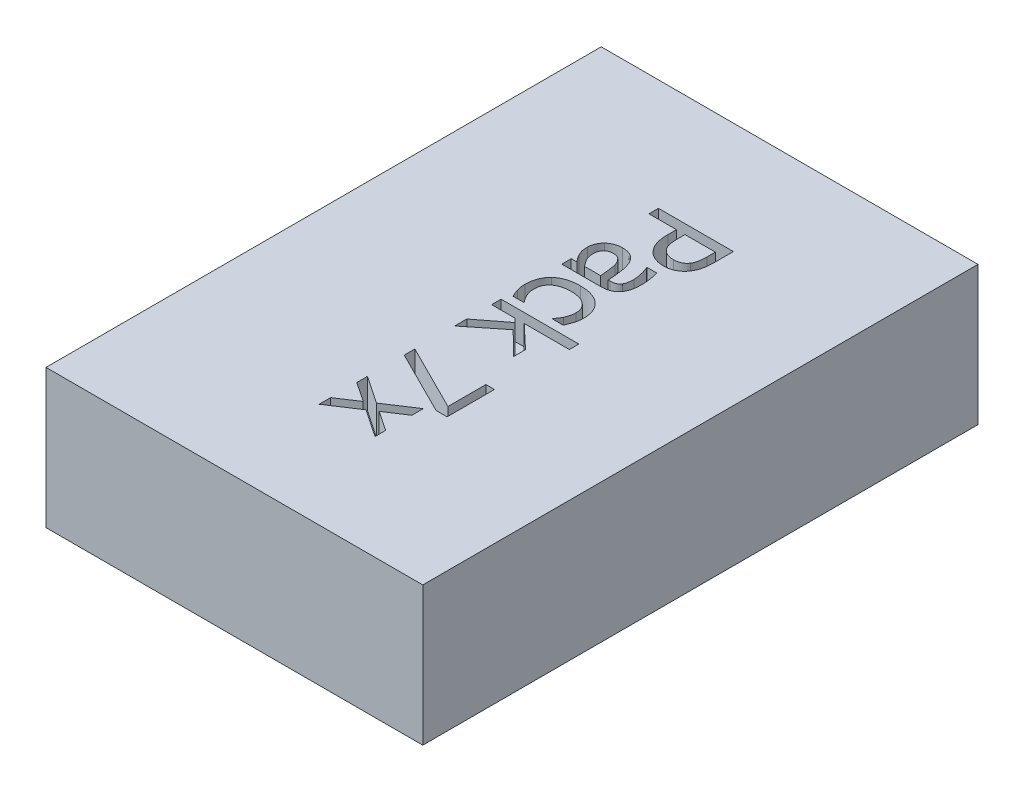
from build123d import *

# Parameters (mm, degrees)
SKETCH1_W           = 38
SKETCH1_H           = 14
BOSS_EXTRUDE1_DEPTH = 56
CUT_EXTRUDE1_DEPTH  = 3


with BuildPart() as part:
    # Sketch1 → Boss-Extrude1 (new body)
    with BuildSketch(Plane.XY):
        Rectangle(SKETCH1_W, SKETCH1_H)
    extrude(amount=BOSS_EXTRUDE1_DEPTH)

    # Sketch2 → Cut-Extrude1 (cut)
    with BuildSketch(Plane(origin=(0, 7, 0), x_dir=(1, 0, 0), z_dir=(0, 1, 0))):
        with BuildLine():
            add(Edge.make_bspline(
                [(3.247819021, -16.001203397), (3.166017395, -15.999505775), (3.003662304, -15.996136435), (2.764297073, -15.959652494), (2.531343241, -15.905343398), (2.307750042, -15.826775929), (2.094742675, -15.731458665), (1.898188136, -15.614545571), (1.715028941, -15.484211033), (1.607405271, -15.381596731), (1.553765815, -15.330453935)],
                knots=[0, 0, 0, 0, 0.000245218, 0.000486695, 0.000724751, 0.000961915, 0.001196573, 0.001423573, 0.00164708, 0.001869161, 0.001869161, 0.001869161, 0.001869161], degree=3))
            add(Edge.make_bspline(
                [(1.553765815, -15.330453935), (1.490690236, -15.263236352), (1.364664717, -15.128935074), (1.208368294, -14.900417457), (1.070026889, -14.658608827), (0.956698106, -14.395418802), (0.869496109, -14.104784869), (0.807935038, -13.782006196), (0.770776554, -13.42414577), (0.766980665, -13.173892861), (0.765000301, -13.04333272)],
                knots=[0, 0, 0, 0, 0.000276157, 0.000551763, 0.000828037, 0.00111109, 0.001409285, 0.001736539, 0.002095523, 0.0024871, 0.0024871, 0.0024871, 0.0024871], degree=3))
            Line((0.765000301, -13.04333272), (0.765000301, -12.176885755))
            Line((0.765000301, -12.176885755), (-2.007629989, -12.176885755))
            Line((-2.007629989, -12.176885755), (-2.007629989, -11.220806344))
            Line((-2.007629989, -11.220806344), (5.545397354, -11.220806344))
            Line((5.545397354, -11.220806344), (5.545397354, -13.122508047))
            add(Edge.make_bspline(
                [(5.545397354, -13.122508047), (5.543922544, -13.230596056), (5.541085497, -13.438521622), (5.520745917, -13.737857764), (5.484996583, -14.012211973), (5.436338134, -14.263551645), (5.371869763, -14.4957725), (5.28927761, -14.711729631), (5.190167504, -14.914523817), (5.108984036, -15.038908552), (5.068851523, -15.100397327)],
                knots=[0, 0, 0, 0, 0.000324257, 0.000623763, 0.000899483, 0.001153784, 0.001391202, 0.001621476, 0.001846621, 0.002066728, 0.002066728, 0.002066728, 0.002066728], degree=3))
            add(Edge.make_bspline(
                [(5.068851523, -15.100397327), (5.018725731, -15.168500818), (4.919494112, -15.303322021), (4.741782651, -15.480824552), (4.545099061, -15.634761619), (4.33037673, -15.768187733), (4.093134351, -15.87411868), (3.832096463, -15.94795925), (3.547686736, -15.993455227), (3.350079722, -15.998561121), (3.247819021, -16.001203397)],
                knots=[0, 0, 0, 0, 0.000253396, 0.000501635, 0.000750579, 0.001001412, 0.001258206, 0.001527224, 0.001813101, 0.002119709, 0.002119709, 0.002119709, 0.002119709], degree=3))
        make_face()
        with BuildLine():
            add(Edge.make_bspline(
                [(3.223917036, -14.949516045), (3.288234658, -14.947762396), (3.412914767, -14.944362936), (3.593401558, -14.91911716), (3.760270828, -14.875733826), (3.914536132, -14.815704042), (4.056140104, -14.738447022), (4.182183333, -14.640530147), (4.29865251, -14.528938843), (4.360661088, -14.440278397), (4.392126565, -14.395288762)],
                knots=[0, 0, 0, 0, 0.000192918, 0.000373973, 0.000545359, 0.000709032, 0.00086951, 0.001027268, 0.001186777, 0.001351103, 0.001351103, 0.001351103, 0.001351103], degree=3))
            add(Edge.make_bspline(
                [(4.392126565, -14.395288762), (4.418174298, -14.354073576), (4.471060507, -14.270392013), (4.529750909, -14.131861513), (4.582469222, -13.985767795), (4.620244151, -13.82673694), (4.650434169, -13.653165097), (4.670764223, -13.461036231), (4.682178311, -13.24962905), (4.683986018, -13.102106481), (4.684925885, -13.025406231)],
                knots=[0, 0, 0, 0, 0.000146033, 0.0002965, 0.00045005, 0.000611644, 0.000786018, 0.000978374, 0.001190841, 0.001420941, 0.001420941, 0.001420941, 0.001420941], degree=3))
            Line((4.684925885, -13.025406231), (4.684925885, -12.176885755))
            Line((4.684925885, -12.176885755), (1.625471771, -12.176885755))
            Line((1.625471771, -12.176885755), (1.625471771, -12.874524949))
            add(Edge.make_bspline(
                [(1.625471771, -12.874524949), (1.626346609, -12.973158383), (1.628009853, -13.160680306), (1.647617026, -13.427003126), (1.678102295, -13.663635985), (1.720536308, -13.873641097), (1.780087162, -14.060852664), (1.860877965, -14.229355242), (1.959716739, -14.382815713), (2.041895714, -14.471082164), (2.082597239, -14.514798688)],
                knots=[0, 0, 0, 0, 0.000295847, 0.000562465, 0.000800573, 0.00101123, 0.001204449, 0.001388202, 0.001570509, 0.001749407, 0.001749407, 0.001749407, 0.001749407], degree=3))
            add(Edge.make_bspline(
                [(2.082597239, -14.514798688), (2.121123908, -14.551129631), (2.196798579, -14.622491424), (2.322642342, -14.711343495), (2.450584854, -14.788752122), (2.585943778, -14.849641585), (2.730138763, -14.894186189), (2.88455006, -14.927137172), (3.05062549, -14.946611097), (3.165105632, -14.948530169), (3.223917036, -14.949516045)],
                knots=[0, 0, 0, 0, 0.000158674, 0.000311671, 0.000461036, 0.000606801, 0.000755628, 0.000912967, 0.001079921, 0.001256299, 0.001256299, 0.001256299, 0.001256299], degree=3))
        make_face(mode=Mode.SUBTRACT)
        with BuildLine():
            add(Edge.make_bspline(
                [(-1.441451713, -20.016736921), (-1.457424795, -19.995851723), (-1.491972199, -19.950680138), (-1.546770282, -19.877237547), (-1.611071154, -19.795090461), (-1.707533725, -19.677384419), (-1.819666444, -19.524797571), (-1.8923424, -19.393561549), (-1.926960789, -19.331048719)],
                knots=[0, 0, 0, 0, 7.8879e-05, 0.000170603, 0.000274897, 0.000391782, 0.000627265, 0.000841468, 0.000841468, 0.000841468, 0.000841468], degree=3))
            add(Edge.make_bspline(
                [(-1.926960789, -19.331048719), (-1.96668949, -19.249517445), (-2.043551674, -19.091780807), (-2.120256143, -18.885527112), (-2.164470294, -18.710076371), (-2.182571356, -18.556613778), (-2.197005924, -18.380224534), (-2.198206, -18.255002519), (-2.198845871, -18.188235049)],
                knots=[0, 0, 0, 0, 0.000272008, 0.000526248, 0.000658496, 0.00081378, 0.000989079, 0.001189309, 0.001189309, 0.001189309, 0.001189309], degree=3))
            add(Edge.make_bspline(
                [(-2.198845871, -18.188235049), (-2.196882187, -18.130898804), (-2.192989252, -18.017231736), (-2.169150981, -17.848782749), (-2.126789357, -17.685237961), (-2.068217129, -17.526857601), (-1.995728061, -17.374949412), (-1.908036094, -17.232289354), (-1.808586593, -17.098143203), (-1.731190509, -17.01822722), (-1.692422559, -16.978197045)],
                knots=[0, 0, 0, 0, 0.000172029, 0.000341042, 0.000509161, 0.000677889, 0.000846935, 0.001013212, 0.001179629, 0.00134665, 0.00134665, 0.00134665, 0.00134665], degree=3))
            add(Edge.make_bspline(
                [(-1.692422559, -16.978197045), (-1.65125364, -16.941539691), (-1.568167503, -16.867558689), (-1.429324361, -16.769834521), (-1.27635256, -16.684866063), (-1.11110933, -16.612586406), (-0.937220773, -16.551966014), (-0.756225836, -16.511230911), (-0.570819051, -16.484469488), (-0.445629909, -16.480998914), (-0.382294991, -16.479243102)],
                knots=[0, 0, 0, 0, 0.000165274, 0.000333552, 0.000508105, 0.000689364, 0.000874079, 0.001059614, 0.001245108, 0.001435041, 0.001435041, 0.001435041, 0.001435041], degree=3))
            add(Edge.make_bspline(
                [(-0.382294991, -16.479243102), (-0.286987744, -16.481820959), (-0.10213739, -16.486820765), (0.163779871, -16.533566762), (0.40801991, -16.611311031), (0.63000501, -16.721721927), (0.833224963, -16.863133933), (1.009552455, -17.044956932), (1.168381083, -17.258992831), (1.249049466, -17.422378107), (1.290843977, -17.507028469)],
                knots=[0, 0, 0, 0, 0.000285721, 0.000554161, 0.000806909, 0.001052095, 0.001295395, 0.001545747, 0.001808686, 0.00209138, 0.00209138, 0.00209138, 0.00209138], degree=3))
            add(Edge.make_bspline(
                [(1.290843977, -17.507028469), (1.326132356, -17.58914532), (1.398562486, -17.75769186), (1.482374065, -18.027999544), (1.549636371, -18.319183154), (1.598163266, -18.630595832), (1.637464118, -18.958680566), (1.671763242, -19.300358567), (1.700334937, -19.654469531), (1.714091732, -19.894705358), (1.721079712, -20.016736921)],
                knots=[0, 0, 0, 0, 0.000267983, 0.00055004, 0.000847546, 0.001163871, 0.001494989, 0.001838807, 0.002193991, 0.002560675, 0.002560675, 0.002560675, 0.002560675], degree=3))
            Line((1.721079712, -20.016736921), (1.904826224, -20.016736921))
            add(Edge.make_bspline(
                [(1.904826224, -20.016736921), (1.958682079, -20.015897713), (2.060813641, -20.014306248), (2.205880092, -19.994220451), (2.335011277, -19.963908315), (2.44907108, -19.920127409), (2.548850155, -19.86482269), (2.634449303, -19.7974387), (2.711344345, -19.723559287), (2.750346816, -19.664983629), (2.769779316, -19.635799031)],
                knots=[0, 0, 0, 0, 0.000161449, 0.00030617, 0.000438418, 0.000558542, 0.000671574, 0.000779144, 0.000884777, 0.000989667, 0.000989667, 0.000989667, 0.000989667], degree=3))
            add(Edge.make_bspline(
                [(2.769779316, -19.635799031), (2.788486, -19.604839727), (2.827064035, -19.540993611), (2.870822358, -19.435352306), (2.903987776, -19.319437768), (2.934155276, -19.15130751), (2.959540905, -18.93044839), (2.96249142, -18.751008581), (2.963982946, -18.660299258)],
                knots=[0, 0, 0, 0, 0.000108396, 0.000223541, 0.000341736, 0.000469478, 0.000735576, 0.001007609, 0.001007609, 0.001007609, 0.001007609], degree=3))
            add(Edge.make_bspline(
                [(2.963982946, -18.660299258), (2.962710327, -18.603494173), (2.960058949, -18.485146274), (2.941233847, -18.300518524), (2.909098284, -18.101781507), (2.850834842, -17.815739472), (2.753132051, -17.44592558), (2.639306518, -17.158431371), (2.581551182, -17.012556148)],
                knots=[0, 0, 0, 0, 0.000170406, 0.000355025, 0.000556172, 0.000774145, 0.001230755, 0.001701088, 0.001701088, 0.001701088, 0.001701088], degree=3))
            Line((2.581551182, -17.012556148), (2.581551182, -16.957282808))
            Line((2.581551182, -16.957282808), (3.563026451, -16.957282808))
            add(Edge.make_bspline(
                [(3.563026451, -16.957282808), (3.576206078, -17.005523929), (3.605046727, -17.111088781), (3.646565168, -17.284405914), (3.689436514, -17.486218598), (3.733698946, -17.711078434), (3.77362351, -17.949481382), (3.804440574, -18.192049394), (3.820403866, -18.433508801), (3.823110733, -18.594051249), (3.824454415, -18.673744124)],
                knots=[0, 0, 0, 0, 0.000150021, 0.000328287, 0.000534561, 0.000768942, 0.001015761, 0.001259606, 0.001502171, 0.001741266, 0.001741266, 0.001741266, 0.001741266], degree=3))
            add(Edge.make_bspline(
                [(3.824454415, -18.673744124), (3.823190404, -18.766379215), (3.820762184, -18.944335122), (3.805690684, -19.199871862), (3.775028282, -19.432642427), (3.735871997, -19.645826397), (3.680743874, -19.842975358), (3.605728257, -20.026970619), (3.51656203, -20.203056793), (3.439959915, -20.309923221), (3.401688051, -20.363315708)],
                knots=[0, 0, 0, 0, 0.000277925, 0.000533905, 0.000767375, 0.000981839, 0.001183755, 0.001380158, 0.00157727, 0.001774082, 0.001774082, 0.001774082, 0.001774082], degree=3))
            add(Edge.make_bspline(
                [(3.401688051, -20.363315708), (3.361142679, -20.412324931), (3.280051936, -20.510343378), (3.135205964, -20.635775228), (2.973321945, -20.741583191), (2.793824889, -20.826997021), (2.595502203, -20.892662341), (2.37777218, -20.940066388), (2.139122708, -20.968507132), (1.973128111, -20.97134313), (1.886899735, -20.972816332)],
                knots=[0, 0, 0, 0, 0.000190561, 0.000381122, 0.000572134, 0.000769246, 0.000975687, 0.001197511, 0.001436727, 0.001695323, 0.001695323, 0.001695323, 0.001695323], degree=3))
            Line((1.886899735, -20.972816332), (-2.007629989, -20.972816332))
            Line((-2.007629989, -20.972816332), (-2.007629989, -20.016736921))
            Line((-2.007629989, -20.016736921), (-1.441451713, -20.016736921))
        make_face()
        with BuildLine():
            Line((-0.655673948, -20.016736921), (0.956216184, -20.016736921))
            add(Edge.make_bspline(
                [(0.956216184, -20.016736921), (0.950957813, -19.955964744), (0.939830484, -19.827363682), (0.91746737, -19.623440767), (0.89645224, -19.397123394), (0.869720185, -19.156138813), (0.842103424, -18.915723862), (0.808391693, -18.692301147), (0.769118156, -18.493513085), (0.734842069, -18.371307301), (0.718690205, -18.313720471)],
                knots=[0, 0, 0, 0, 0.000182992, 0.000387232, 0.000615404, 0.000864841, 0.001114617, 0.001341317, 0.001542592, 0.001721962, 0.001721962, 0.001721962, 0.001721962], degree=3))
            add(Edge.make_bspline(
                [(0.718690205, -18.313720471), (0.697688107, -18.252415467), (0.656605887, -18.132496703), (0.572491778, -17.96557042), (0.470584256, -17.816785222), (0.357077393, -17.681331174), (0.219845868, -17.56946), (0.056205907, -17.491048186), (-0.130483758, -17.441941861), (-0.263452511, -17.437595647), (-0.332997147, -17.435322513)],
                knots=[0, 0, 0, 0, 0.000194255, 0.000379983, 0.000558562, 0.00073437, 0.000908648, 0.001085027, 0.00127489, 0.001483075, 0.001483075, 0.001483075, 0.001483075], degree=3))
            add(Edge.make_bspline(
                [(-0.332997147, -17.435322513), (-0.373351338, -17.43629552), (-0.45125674, -17.43817395), (-0.564969711, -17.449448034), (-0.670253823, -17.472252879), (-0.769052149, -17.501986966), (-0.859593419, -17.540743291), (-0.94370277, -17.587051689), (-1.018000468, -17.644624734), (-1.108926706, -17.730691437), (-1.203751371, -17.862918048), (-1.282223106, -18.052418779), (-1.330094258, -18.272545181), (-1.335511831, -18.429482305), (-1.338374402, -18.512405724)],
                knots=[0, 0, 0, 0, 0.000121087, 0.000233763, 0.000342169, 0.000443764, 0.000542822, 0.000637138, 0.000730955, 0.000823936, 0.001012188, 0.001213639, 0.001435463, 0.00168399, 0.00168399, 0.00168399, 0.00168399], degree=3))
            add(Edge.make_bspline(
                [(-1.338374402, -18.512405724), (-1.336368286, -18.586291243), (-1.332437283, -18.731070576), (-1.292839141, -18.942499699), (-1.233124579, -19.144082166), (-1.143467473, -19.332952126), (-1.038651645, -19.513093683), (-0.920881088, -19.686638562), (-0.79473245, -19.856013894), (-0.702161032, -19.963007413), (-0.655673948, -20.016736921)],
                knots=[0, 0, 0, 0, 0.000221416, 0.000433867, 0.000643207, 0.000850419, 0.001059247, 0.001268069, 0.001479303, 0.001692383, 0.001692383, 0.001692383, 0.001692383], degree=3))
        make_face(mode=Mode.SUBTRACT)
        with BuildLine():
            add(Edge.make_bspline(
                [(-2.10323793, -24.562595744), (-2.100764893, -24.467399402), (-2.095920274, -24.280912134), (-2.063051128, -24.006718322), (-2.005887403, -23.745479998), (-1.928755061, -23.495787361), (-1.827824028, -23.260606451), (-1.700623466, -23.043059201), (-1.553533674, -22.839998159), (-1.436111287, -22.721715544), (-1.377215128, -22.662387916)],
                knots=[0, 0, 0, 0, 0.00028558, 0.000559444, 0.000826965, 0.00108683, 0.001342422, 0.001592756, 0.001841642, 0.002092101, 0.002092101, 0.002092101, 0.002092101], degree=3))
            add(Edge.make_bspline(
                [(-1.377215128, -22.662387916), (-1.313673882, -22.6061265), (-1.184521663, -22.491771069), (-0.964883671, -22.345382187), (-0.720155845, -22.222116461), (-0.453824254, -22.115055659), (-0.161866683, -22.032109891), (0.153859849, -21.970971941), (0.494288656, -21.935330072), (0.729062281, -21.931085143), (0.850151124, -21.928895743)],
                knots=[0, 0, 0, 0, 0.000254398, 0.000517082, 0.000789004, 0.001075286, 0.00137693, 0.001698033, 0.002039033, 0.002402241, 0.002402241, 0.002402241, 0.002402241], degree=3))
            add(Edge.make_bspline(
                [(0.850151124, -21.928895743), (0.97026461, -21.930925912), (1.203145224, -21.934862082), (1.539509153, -21.972559569), (1.851006206, -22.033958002), (2.136160005, -22.123708073), (2.398887118, -22.230715281), (2.638762239, -22.357323036), (2.859119234, -22.497758538), (2.989502734, -22.608120381), (3.053615391, -22.662387916)],
                knots=[0, 0, 0, 0, 0.000360222, 0.000698412, 0.001013945, 0.001311151, 0.001593841, 0.001863798, 0.002124011, 0.00237575, 0.00237575, 0.00237575, 0.00237575], degree=3))
            add(Edge.make_bspline(
                [(3.053615391, -22.662387916), (3.113455645, -22.719692119), (3.233873841, -22.83500695), (3.38671586, -23.035792313), (3.519400798, -23.255717154), (3.628873286, -23.494612855), (3.716738304, -23.747187769), (3.779711905, -24.010856037), (3.818095574, -24.283593967), (3.822317918, -24.468854347), (3.824454415, -24.562595744)],
                knots=[0, 0, 0, 0, 0.000248239, 0.000499539, 0.0007542, 0.001017546, 0.001286364, 0.001555216, 0.001829654, 0.002110756, 0.002110756, 0.002110756, 0.002110756], degree=3))
            add(Edge.make_bspline(
                [(3.824454415, -24.562595744), (3.823358165, -24.639866696), (3.821187765, -24.792850689), (3.793478004, -25.019749285), (3.754918591, -25.242960972), (3.69502676, -25.459605192), (3.626960944, -25.668031936), (3.552662946, -25.866436064), (3.477048469, -26.054517271), (3.418355671, -26.173323275), (3.389737058, -26.23125309)],
                knots=[0, 0, 0, 0, 0.000231671, 0.000458671, 0.000684883, 0.000910636, 0.001132198, 0.001342538, 0.001546165, 0.001739938, 0.001739938, 0.001739938, 0.001739938], degree=3))
            Line((3.389737058, -26.23125309), (2.294727358, -26.23125309))
            Line((2.294727358, -26.23125309), (2.294727358, -26.174485875))
            add(Edge.make_bspline(
                [(2.294727358, -26.174485875), (2.325433744, -26.135896876), (2.393054021, -26.050917848), (2.496617453, -25.904752431), (2.608637808, -25.726938217), (2.677728577, -25.592973214), (2.714505975, -25.521662903)],
                knots=[0, 0, 0, 0, 0.000147924, 0.000325751, 0.000537149, 0.000777751, 0.000777751, 0.000777751, 0.000777751], degree=3))
            add(Edge.make_bspline(
                [(2.714505975, -25.521662903), (2.747439044, -25.450057351), (2.817330328, -25.298094472), (2.892588593, -25.051223165), (2.953719106, -24.793462128), (2.960637491, -24.617706611), (2.963982946, -24.532718262)],
                knots=[0, 0, 0, 0, 0.000236174, 0.000501213, 0.000773115, 0.001027705, 0.001027705, 0.001027705, 0.001027705], degree=3))
            add(Edge.make_bspline(
                [(2.963982946, -24.532718262), (2.962223067, -24.471880724), (2.958788282, -24.353143104), (2.9329873, -24.179209049), (2.889605441, -24.015038085), (2.830196515, -23.858725809), (2.749371656, -23.714240653), (2.655727314, -23.576482685), (2.541416031, -23.450426109), (2.412178976, -23.332927457), (2.267103893, -23.226143874), (2.106002834, -23.135493093), (1.931540606, -23.057322907), (1.743025739, -22.993311949), (1.54005877, -22.943942062), (1.322616258, -22.91054993), (1.091086352, -22.889279264), (0.931864839, -22.886434902), (0.850151124, -22.884975153)],
                knots=[0, 0, 0, 0, 0.000182473, 0.000356135, 0.000526076, 0.000691141, 0.000856266, 0.001021608, 0.001189833, 0.001365387, 0.001544963, 0.001728958, 0.001918862, 0.00211775, 0.002325361, 0.002544681, 0.002777174, 0.003022283, 0.003022283, 0.003022283, 0.003022283], degree=3))
            add(Edge.make_bspline(
                [(0.850151124, -22.884975153), (0.769950288, -22.886632652), (0.61379209, -22.88985995), (0.386501372, -22.908375216), (0.172957577, -22.943295745), (-0.027138069, -22.99013367), (-0.213836604, -23.052168751), (-0.387948434, -23.12558205), (-0.546484624, -23.216669989), (-0.692774525, -23.31716497), (-0.820613156, -23.43309913), (-0.934627509, -23.557699689), (-1.030489691, -23.694230076), (-1.108895199, -23.84172417), (-1.168460844, -24.000095197), (-1.212101395, -24.168249038), (-1.237507781, -24.347203978), (-1.24098564, -24.469894954), (-1.242766461, -24.532718262)],
                knots=[0, 0, 0, 0, 0.00024063, 0.000468528, 0.000683422, 0.00088923, 0.001084334, 0.001273036, 0.001454994, 0.00163196, 0.001804404, 0.001971517, 0.002137714, 0.002303446, 0.0024713, 0.002644131, 0.002823707, 0.003012148, 0.003012148, 0.003012148, 0.003012148], degree=3))
            add(Edge.make_bspline(
                [(-1.242766461, -24.532718262), (-1.24039115, -24.610028514), (-1.235678248, -24.763421318), (-1.200187408, -24.990810352), (-1.142141105, -25.212772845), (-1.059504511, -25.426736592), (-0.958561349, -25.631024822), (-0.84596111, -25.825900271), (-0.716974056, -26.007199678), (-0.621173881, -26.118908109), (-0.573510873, -26.174485875)],
                knots=[0, 0, 0, 0, 0.000231859, 0.000460035, 0.000688676, 0.000918951, 0.001146775, 0.001371731, 0.001593495, 0.001813074, 0.001813074, 0.001813074, 0.001813074], degree=3))
            Line((-0.573510873, -26.174485875), (-0.573510873, -26.23125309))
            Line((-0.573510873, -26.23125309), (-1.659557329, -26.23125309))
            add(Edge.make_bspline(
                [(-1.659557329, -26.23125309), (-1.684022806, -26.177997952), (-1.738081447, -26.060326004), (-1.820870271, -25.876255851), (-1.900728133, -25.685037996), (-1.938956724, -25.554390215), (-1.956838271, -25.493279295)],
                knots=[0, 0, 0, 0, 0.000175808, 0.000388464, 0.000605672, 0.000796561, 0.000796561, 0.000796561, 0.000796561], degree=3))
            add(Edge.make_bspline(
                [(-1.956838271, -25.493279295), (-1.978310622, -25.416752401), (-2.018677821, -25.272884761), (-2.061148588, -25.093445873), (-2.084027486, -24.950923289), (-2.09581839, -24.833730497), (-2.100890129, -24.702564472), (-2.102427691, -24.610899734), (-2.10323793, -24.562595744)],
                knots=[0, 0, 0, 0, 0.000238459, 0.000448294, 0.000552673, 0.000671292, 0.000801397, 0.000946333, 0.000946333, 0.000946333, 0.000946333], degree=3))
        make_face()
        Polygon((-2.007629989, -31.776513672), (-2.007629989, -30.551536927), (0.726159575, -28.442186727), (0.351197182, -28.047803971), (-2.007629989, -28.047803971), (-2.007629989, -27.09172456), (5.832221178, -27.09172456), (5.832221178, -28.047803971), (1.277399111, -28.047803971), (3.633238533, -30.269194726), (3.633238533, -31.489689849), (1.274411362, -29.153270789), align=None)
        Polygon((4.439930536, -40.094404544), (-2.007629989, -36.863154911), (-2.007629989, -35.792047196), (4.684925885, -39.145794504), (4.684925885, -35.314007491), (5.545397354, -35.314007491), (5.545397354, -40.094404544), align=None)
        Polygon((-2.007629989, -45.448449243), (-2.007629989, -44.289202958), (-0.025259086, -42.980569265), (-2.007629989, -41.645045838), (-2.007629989, -40.572444249), (0.781432916, -42.451737841), (3.633238533, -40.572444249), (3.633238533, -41.733184409), (1.649373756, -43.038830354), (3.633238533, -44.377341529), (3.633238533, -45.448449243), (0.847163376, -43.569155652), align=None)
    extrude(amount=-CUT_EXTRUDE1_DEPTH, mode=Mode.SUBTRACT)


solid = part.part
